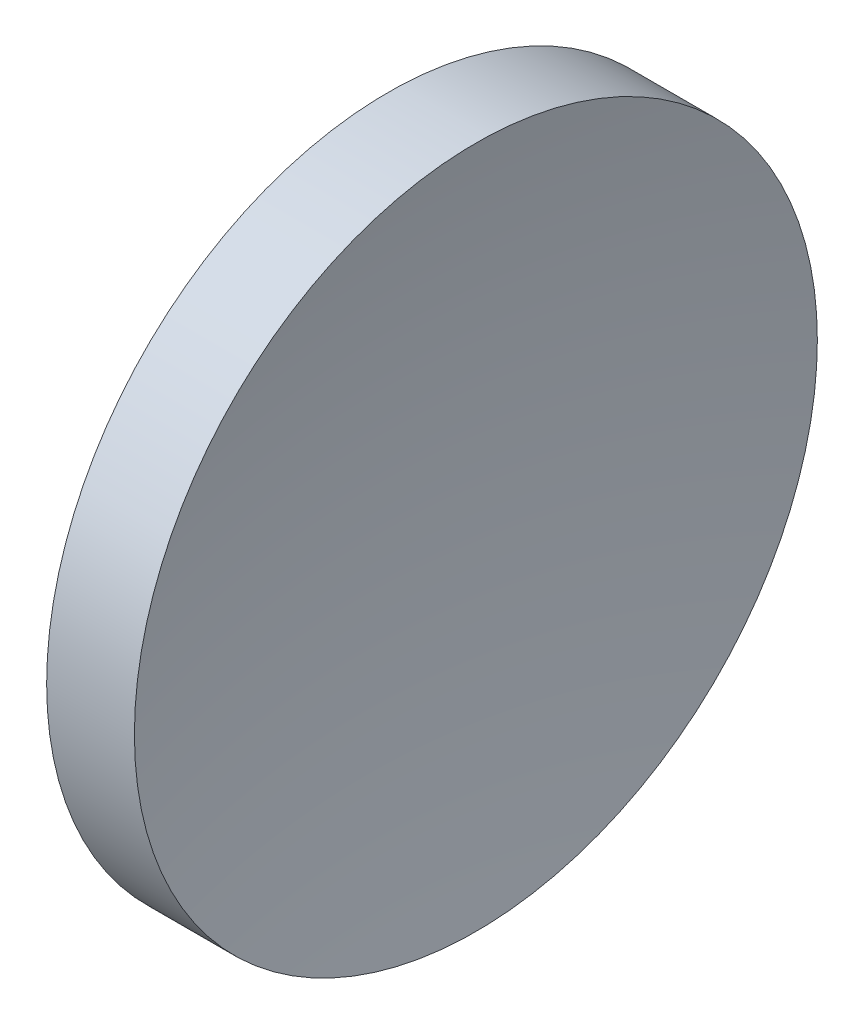
from build123d import *


with BuildPart() as part:
    # 草图1 → 旋转1 (revolve)
    with BuildSketch(Plane.XY, mode=Mode.PRIVATE) as revolve_1_sk:
        with BuildLine():
            Line((57.532337053, 32.610768129), (57.532337053, 45.110768129))
            Line((57.532337053, 45.110768129), (60.744927958, 45.110768129))
            ThreePointArc((60.744927958, 45.110768129), (59.833914024, 38.890328038), (59.532337053, 32.610768129))
            Line((59.532337053, 32.610768129), (57.532337053, 32.610768129))
        make_face()
    revolve(revolve_1_sk.sketch.rotate(Axis((56.10091508, 32.610768129, 0), (1, 0, 0)), 90), axis=Axis((56.10091508, 32.610768129, 0), (1, 0, 0)))  # turned: the seam where the file's is


solid = part.part
